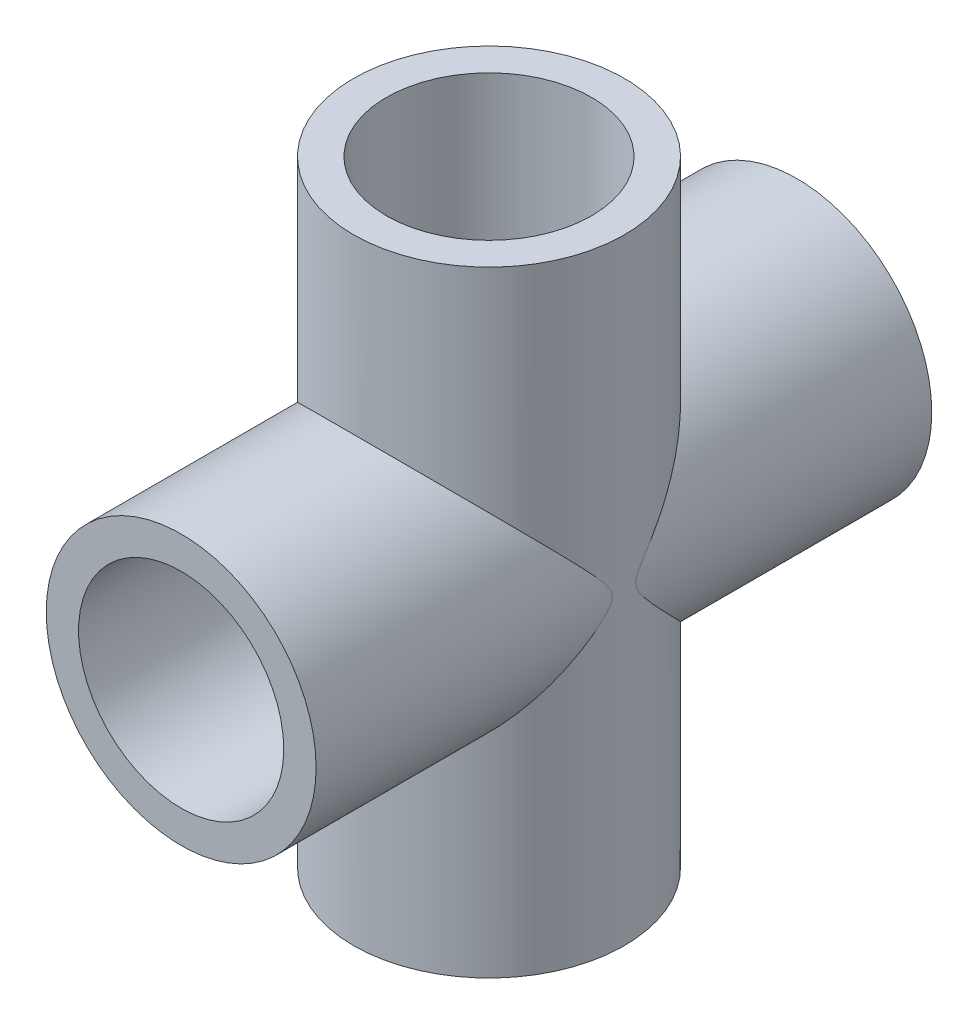
from build123d import *

# Parameters (mm, degrees)
SKETCH1_R               = 16.7005
SKETCH1_R_2             = 12.7
BOSS_EXTRUDE1_DEPTH     = 76.2
SKETCH2_R               = 16.764
SKETCH2_R_2             = 12.7
BOSS_EXTRUDE2_DEPTH     = 38.1
CUT_EXTRUDE3_REACH      = 78.2
SKETCH5_R               = 12.7
SKETCH6_R               = 12.7
CUT_EXTRUDE4_DEPTH      = 1.0000001
CUT_EXTRUDE4_DEPTH_BACK = 77.2000001
SKETCH7_R               = 12.7
CUT_EXTRUDE5_DEPTH      = 77.2000001


with BuildPart() as part:
    # Sketch1 → Boss-Extrude1 (new body)
    with BuildSketch(Plane.XY):
        Circle(SKETCH1_R)
        Circle(SKETCH1_R_2, mode=Mode.SUBTRACT)
    extrude(amount=BOSS_EXTRUDE1_DEPTH)

    # Sketch2 → Boss-Extrude2 (add, symmetric)
    with BuildSketch(Plane(origin=(0, 0, 0), x_dir=(1, 0, 0), z_dir=(0, 1, 0))):
        with Locations((0, -38.1)):
            Circle(SKETCH2_R)
        with Locations((0, -38.1)):
            Circle(SKETCH2_R_2, mode=Mode.SUBTRACT)
    extrude(amount=BOSS_EXTRUDE2_DEPTH, both=True)

    # Sketch5 → Cut-Extrude3 (cut, up to next)
    with BuildSketch(Plane(origin=(0, 38.1, 0), x_dir=(1, 0, 0), z_dir=(0, 1, 0)), mode=Mode.PRIVATE) as cut_extrude3_sk1:
        with Locations((0, -38.1)):
            Circle(SKETCH5_R)
    cut_extrude3_tool1 = extrude(cut_extrude3_sk1.sketch, amount=-CUT_EXTRUDE3_REACH, mode=Mode.PRIVATE) & part.part
    add(cut_extrude3_tool1.solids().sort_by_distance((0, 38.1, 38.1))[0], mode=Mode.SUBTRACT)

    # Sketch6 → Cut-Extrude4 (cut, two sides)
    with BuildSketch(Plane(origin=(0, 0, 0), x_dir=(-1, 0, 0), z_dir=(0, 0, -1))) as cut_extrude4_sk:
        Circle(SKETCH6_R)
    extrude(amount=CUT_EXTRUDE4_DEPTH, mode=Mode.SUBTRACT)
    extrude(cut_extrude4_sk.sketch, amount=-CUT_EXTRUDE4_DEPTH_BACK, mode=Mode.SUBTRACT)

    # Sketch7 → Cut-Extrude5 (cut, through all)
    with BuildSketch(Plane.XZ.offset(38.1)):
        with Locations((0, 38.1)):
            Circle(SKETCH7_R)
    extrude(amount=-CUT_EXTRUDE5_DEPTH, mode=Mode.SUBTRACT)


solid = part.part
